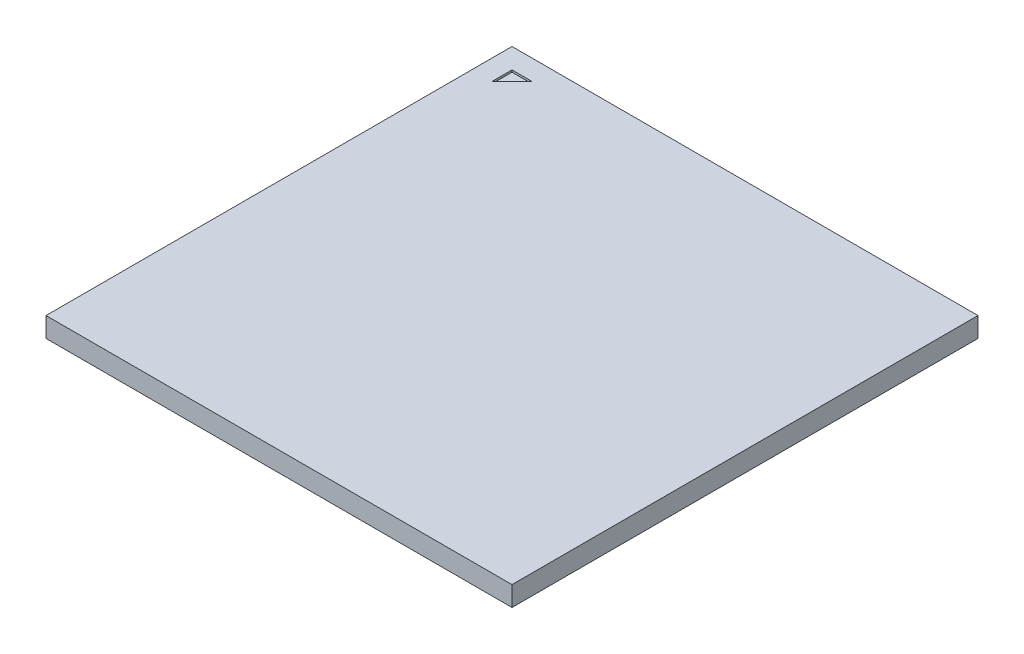
from build123d import *

# Parameters (mm, degrees)
SKETCH1_W           = 23
SKETCH1_H           = 23
BOSS_EXTRUDE1_DEPTH = 0.98
CUT_EXTRUDE1_DEPTH  = 0.1


with BuildPart() as part:
    # Sketch1 → Boss-Extrude1 (new body)
    with BuildSketch(Plane(origin=(0, 0, 0), x_dir=(1, 0, 0), z_dir=(0, 1, 0))):
        Rectangle(SKETCH1_W, SKETCH1_H)
    extrude(amount=BOSS_EXTRUDE1_DEPTH)

    # Sketch2 → Cut-Extrude1 (cut)
    with BuildSketch(Plane(origin=(0, 0.98, 0), x_dir=(1, 0, 0), z_dir=(0, 1, 0))):
        Polygon((-10.5, 10.5), (-9.5, 10.5), (-10.5, 9.5), align=None)
    extrude(amount=-CUT_EXTRUDE1_DEPTH, mode=Mode.SUBTRACT)


solid = part.part
